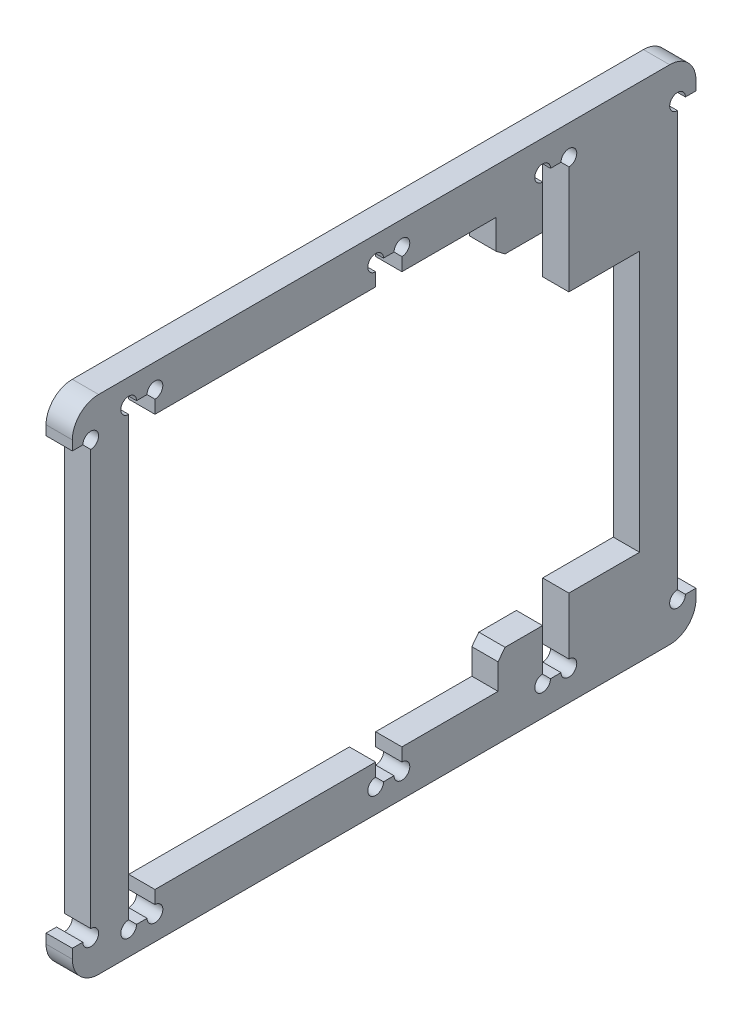
from build123d import *

# Parameters (mm, degrees)
BOSS_EXTRUDE1_DEPTH = 5
FILLET1_R           = 5
CUT_EXTRUDE1_REACH  = 7
SKETCH2_W           = 5
SKETCH2_H           = 4
CUT_EXTRUDE2_REACH  = 7
SKETCH3_R           = 1.5


with BuildPart() as part:
    # Sketch1 → Boss-Extrude1 (new body)
    with BuildSketch(Plane(origin=(0, 0, 0), x_dir=(0, 0, -1), z_dir=(1, 0, 0))):
        Polygon((-59.36916415, -47.818646587), (0, -47.818646587), (59.36916415, -47.818646587), (59.36916415, -41), (55.86916415, -41), (55.86916415, 41), (59.36916415, 41), (59.36916415, 47.818646587), (-59.36916415, 47.818646587), (-59.36916415, 41), (-55.86916415, 41), (-55.86916415, -41), (-59.36916415, -41), align=None)
        Polygon((21.702610628, -39.175443067), (21.702610628, -34.307045578), (23.024909313, -32.569779859), (30.179141539, -32.569779859), (30.179141539, -42.076978078), (35.179141539, -42.076978078), (35.179141539, -29.710380013), (48.63820865, -29.710380013), (48.63820865, 19.945173818), (35.179141539, 19.945173818), (35.179141539, 42.076978078), (30.179141539, 42.076978078), (30.179141539, 32.288188968), (23.024909313, 32.288188968), (21.287643594, 33.610487654), (21.287643594, 39.175443067), (-48.63820865, 39.175443067), (-48.63820865, -39.175443067), align=None, mode=Mode.SUBTRACT)
    extrude(amount=BOSS_EXTRUDE1_DEPTH)

    # Fillet1
    fillet1_edges = [part.edges().sort_by_distance(p)[0] for p in [
        (2.5, -47.818646587, -59.36916415),
        (2.5, -47.818646587, 59.36916415),
        (2.5, 47.818646587, 59.36916415),
        (2.5, 47.818646587, -59.36916415),
    ]]
    fillet(fillet1_edges, radius=FILLET1_R)

    # Sketch2 → Cut-Extrude1 (cut, up to next)
    with BuildSketch(Plane.ZY, mode=Mode.PRIVATE) as cut_extrude1_sk1:
        with Locations((46.13820865, 41.175443067)):
            Rectangle(SKETCH2_W, SKETCH2_H)
    cut_extrude1_tool1 = extrude(cut_extrude1_sk1.sketch, amount=-CUT_EXTRUDE1_REACH, mode=Mode.PRIVATE) & part.part
    add(cut_extrude1_tool1.solids().sort_by_distance((0, 41.175443, 46.138209))[0], mode=Mode.SUBTRACT)
    # Sketch2 → Cut-Extrude1 (cut, up to next)
    with BuildSketch(Plane.ZY, mode=Mode.PRIVATE) as cut_extrude1_sk2:
        with Locations((46.13820865, -41.175443067)):
            Rectangle(SKETCH2_W, SKETCH2_H)
    cut_extrude1_tool2 = extrude(cut_extrude1_sk2.sketch, amount=-CUT_EXTRUDE1_REACH, mode=Mode.PRIVATE) & part.part
    add(cut_extrude1_tool2.solids().sort_by_distance((0, -41.175443, 46.138209))[0], mode=Mode.SUBTRACT)
    # Sketch2 → Cut-Extrude1 (cut, up to next)
    with BuildSketch(Plane.ZY, mode=Mode.PRIVATE) as cut_extrude1_sk3:
        with Locations((-0.884341096, -41.175443067)):
            Rectangle(SKETCH2_W, SKETCH2_H)
    cut_extrude1_tool3 = extrude(cut_extrude1_sk3.sketch, amount=-CUT_EXTRUDE1_REACH, mode=Mode.PRIVATE) & part.part
    add(cut_extrude1_tool3.solids().sort_by_distance((0, -41.175443, -0.884341))[0], mode=Mode.SUBTRACT)
    # Sketch2 → Cut-Extrude1 (cut, up to next)
    with BuildSketch(Plane.ZY, mode=Mode.PRIVATE) as cut_extrude1_sk4:
        with Locations((-0.884341096, 41.175443067)):
            Rectangle(SKETCH2_W, SKETCH2_H)
    cut_extrude1_tool4 = extrude(cut_extrude1_sk4.sketch, amount=-CUT_EXTRUDE1_REACH, mode=Mode.PRIVATE) & part.part
    add(cut_extrude1_tool4.solids().sort_by_distance((0, 41.175443, -0.884341))[0], mode=Mode.SUBTRACT)

    # Sketch3 → Cut-Extrude2 (cut, up to next)
    with BuildSketch(Plane.ZY, mode=Mode.PRIVATE) as cut_extrude2_sk1:
        with Locations((-35.179141539, 42.076978078)):
            Circle(SKETCH3_R)
    cut_extrude2_tool1 = extrude(cut_extrude2_sk1.sketch, amount=-CUT_EXTRUDE2_REACH, mode=Mode.PRIVATE) & part.part
    add(cut_extrude2_tool1.solids().sort_by_distance((0, 42.076978, -35.179142))[0], mode=Mode.SUBTRACT)
    # Sketch3 → Cut-Extrude2 (cut, up to next)
    with BuildSketch(Plane.ZY, mode=Mode.PRIVATE) as cut_extrude2_sk2:
        with Locations((-30.179141539, 42.076978078)):
            Circle(SKETCH3_R)
    cut_extrude2_tool2 = extrude(cut_extrude2_sk2.sketch, amount=-CUT_EXTRUDE2_REACH, mode=Mode.PRIVATE) & part.part
    add(cut_extrude2_tool2.solids().sort_by_distance((0, 42.076978, -30.179142))[0], mode=Mode.SUBTRACT)
    # Sketch3 → Cut-Extrude2 (cut, up to next)
    with BuildSketch(Plane.ZY, mode=Mode.PRIVATE) as cut_extrude2_sk3:
        with Locations((-3.384341096, 43.175443067)):
            Circle(SKETCH3_R)
    cut_extrude2_tool3 = extrude(cut_extrude2_sk3.sketch, amount=-CUT_EXTRUDE2_REACH, mode=Mode.PRIVATE) & part.part
    add(cut_extrude2_tool3.solids().sort_by_distance((0, 43.175443, -3.384341))[0], mode=Mode.SUBTRACT)
    # Sketch3 → Cut-Extrude2 (cut, up to next)
    with BuildSketch(Plane.ZY, mode=Mode.PRIVATE) as cut_extrude2_sk4:
        with Locations((1.615658904, 43.175443067)):
            Circle(SKETCH3_R)
    cut_extrude2_tool4 = extrude(cut_extrude2_sk4.sketch, amount=-CUT_EXTRUDE2_REACH, mode=Mode.PRIVATE) & part.part
    add(cut_extrude2_tool4.solids().sort_by_distance((0, 43.175443, 1.615659))[0], mode=Mode.SUBTRACT)
    # Sketch3 → Cut-Extrude2 (cut, up to next)
    with BuildSketch(Plane.ZY, mode=Mode.PRIVATE) as cut_extrude2_sk5:
        with Locations((-55.86916415, 41)):
            Circle(SKETCH3_R)
    cut_extrude2_tool5 = extrude(cut_extrude2_sk5.sketch, amount=-CUT_EXTRUDE2_REACH, mode=Mode.PRIVATE) & part.part
    add(cut_extrude2_tool5.solids().sort_by_distance((0, 41, -55.869164))[0], mode=Mode.SUBTRACT)
    # Sketch3 → Cut-Extrude2 (cut, up to next)
    with BuildSketch(Plane.ZY, mode=Mode.PRIVATE) as cut_extrude2_sk6:
        with Locations((43.63820865, 43.175443067)):
            Circle(SKETCH3_R)
    cut_extrude2_tool6 = extrude(cut_extrude2_sk6.sketch, amount=-CUT_EXTRUDE2_REACH, mode=Mode.PRIVATE) & part.part
    add(cut_extrude2_tool6.solids().sort_by_distance((0, 43.175443, 43.638209))[0], mode=Mode.SUBTRACT)
    # Sketch3 → Cut-Extrude2 (cut, up to next)
    with BuildSketch(Plane.ZY, mode=Mode.PRIVATE) as cut_extrude2_sk7:
        with Locations((48.63820865, 43.175443067)):
            Circle(SKETCH3_R)
    cut_extrude2_tool7 = extrude(cut_extrude2_sk7.sketch, amount=-CUT_EXTRUDE2_REACH, mode=Mode.PRIVATE) & part.part
    add(cut_extrude2_tool7.solids().sort_by_distance((0, 43.175443, 48.638209))[0], mode=Mode.SUBTRACT)
    # Sketch3 → Cut-Extrude2 (cut, up to next)
    with BuildSketch(Plane.ZY, mode=Mode.PRIVATE) as cut_extrude2_sk8:
        with Locations((48.63820865, -43.175443067)):
            Circle(SKETCH3_R)
    cut_extrude2_tool8 = extrude(cut_extrude2_sk8.sketch, amount=-CUT_EXTRUDE2_REACH, mode=Mode.PRIVATE) & part.part
    add(cut_extrude2_tool8.solids().sort_by_distance((0, -43.175443, 48.638209))[0], mode=Mode.SUBTRACT)
    # Sketch3 → Cut-Extrude2 (cut, up to next)
    with BuildSketch(Plane.ZY, mode=Mode.PRIVATE) as cut_extrude2_sk9:
        with Locations((43.63820865, -43.175443067)):
            Circle(SKETCH3_R)
    cut_extrude2_tool9 = extrude(cut_extrude2_sk9.sketch, amount=-CUT_EXTRUDE2_REACH, mode=Mode.PRIVATE) & part.part
    add(cut_extrude2_tool9.solids().sort_by_distance((0, -43.175443, 43.638209))[0], mode=Mode.SUBTRACT)
    # Sketch3 → Cut-Extrude2 (cut, up to next)
    with BuildSketch(Plane.ZY, mode=Mode.PRIVATE) as cut_extrude2_sk10:
        with Locations((1.615658904, -43.175443067)):
            Circle(SKETCH3_R)
    cut_extrude2_tool10 = extrude(cut_extrude2_sk10.sketch, amount=-CUT_EXTRUDE2_REACH, mode=Mode.PRIVATE) & part.part
    add(cut_extrude2_tool10.solids().sort_by_distance((0, -43.175443, 1.615659))[0], mode=Mode.SUBTRACT)
    # Sketch3 → Cut-Extrude2 (cut, up to next)
    with BuildSketch(Plane.ZY, mode=Mode.PRIVATE) as cut_extrude2_sk11:
        with Locations((-3.384341096, -43.175443067)):
            Circle(SKETCH3_R)
    cut_extrude2_tool11 = extrude(cut_extrude2_sk11.sketch, amount=-CUT_EXTRUDE2_REACH, mode=Mode.PRIVATE) & part.part
    add(cut_extrude2_tool11.solids().sort_by_distance((0, -43.175443, -3.384341))[0], mode=Mode.SUBTRACT)
    # Sketch3 → Cut-Extrude2 (cut, up to next)
    with BuildSketch(Plane.ZY, mode=Mode.PRIVATE) as cut_extrude2_sk12:
        with Locations((-30.179141539, -42.076978078)):
            Circle(SKETCH3_R)
    cut_extrude2_tool12 = extrude(cut_extrude2_sk12.sketch, amount=-CUT_EXTRUDE2_REACH, mode=Mode.PRIVATE) & part.part
    add(cut_extrude2_tool12.solids().sort_by_distance((0, -42.076978, -30.179142))[0], mode=Mode.SUBTRACT)
    # Sketch3 → Cut-Extrude2 (cut, up to next)
    with BuildSketch(Plane.ZY, mode=Mode.PRIVATE) as cut_extrude2_sk13:
        with Locations((-35.179141539, -42.076978078)):
            Circle(SKETCH3_R)
    cut_extrude2_tool13 = extrude(cut_extrude2_sk13.sketch, amount=-CUT_EXTRUDE2_REACH, mode=Mode.PRIVATE) & part.part
    add(cut_extrude2_tool13.solids().sort_by_distance((0, -42.076978, -35.179142))[0], mode=Mode.SUBTRACT)
    # Sketch3 → Cut-Extrude2 (cut, up to next)
    with BuildSketch(Plane.ZY, mode=Mode.PRIVATE) as cut_extrude2_sk14:
        with Locations((-55.86916415, -41)):
            Circle(SKETCH3_R)
    cut_extrude2_tool14 = extrude(cut_extrude2_sk14.sketch, amount=-CUT_EXTRUDE2_REACH, mode=Mode.PRIVATE) & part.part
    add(cut_extrude2_tool14.solids().sort_by_distance((0, -41, -55.869164))[0], mode=Mode.SUBTRACT)
    # Sketch3 → Cut-Extrude2 (cut, up to next)
    with BuildSketch(Plane.ZY, mode=Mode.PRIVATE) as cut_extrude2_sk15:
        with Locations((55.86916415, -41)):
            Circle(SKETCH3_R)
    cut_extrude2_tool15 = extrude(cut_extrude2_sk15.sketch, amount=-CUT_EXTRUDE2_REACH, mode=Mode.PRIVATE) & part.part
    add(cut_extrude2_tool15.solids().sort_by_distance((0, -41, 55.869164))[0], mode=Mode.SUBTRACT)
    # Sketch3 → Cut-Extrude2 (cut, up to next)
    with BuildSketch(Plane.ZY, mode=Mode.PRIVATE) as cut_extrude2_sk16:
        with Locations((55.86916415, 41)):
            Circle(SKETCH3_R)
    cut_extrude2_tool16 = extrude(cut_extrude2_sk16.sketch, amount=-CUT_EXTRUDE2_REACH, mode=Mode.PRIVATE) & part.part
    add(cut_extrude2_tool16.solids().sort_by_distance((0, 41, 55.869164))[0], mode=Mode.SUBTRACT)


solid = part.part
